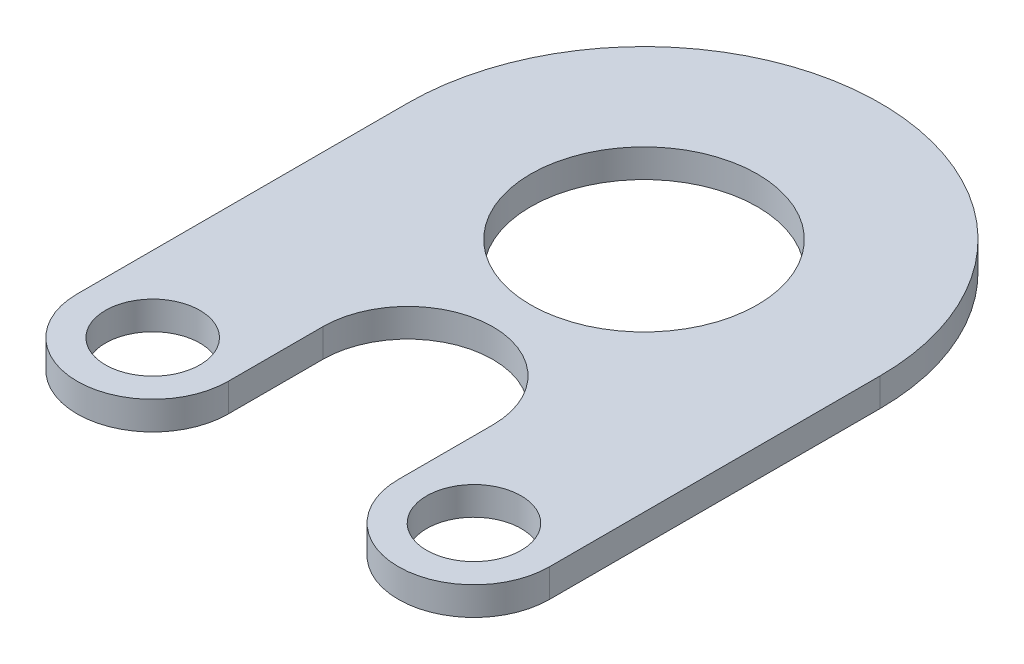
from build123d import *

# Parameters (mm, degrees)
SKETCH1_R           = 12
SKETCH1_R_2         = 5
BOSS_EXTRUDE2_DEPTH = 1.5


with BuildPart() as part:
    # Sketch1 → Boss-Extrude2 (new body, symmetric)
    with BuildSketch(Plane(origin=(0, 0, 0), x_dir=(1, 0, 0), z_dir=(0, 1, 0))):
        with BuildLine():
            Line((-25, 0), (-25, -35))
            ThreePointArc((-25, -35), (-17, -43), (-9, -35))
            Line((-9, -35), (-9, -25))
            ThreePointArc((-9, -25), (0, -16), (9, -25))
            Line((9, -25), (9, -35))
            ThreePointArc((9, -35), (17, -43), (25, -35))
            Line((25, -35), (25, 0))
            ThreePointArc((25, 0), (0, 25), (-25, 0))
        make_face()
        Circle(SKETCH1_R, mode=Mode.SUBTRACT)
        with Locations((17, -35)):
            Circle(SKETCH1_R_2, mode=Mode.SUBTRACT)
        with Locations((-17, -35)):
            Circle(SKETCH1_R_2, mode=Mode.SUBTRACT)
    extrude(amount=BOSS_EXTRUDE2_DEPTH, both=True)


solid = part.part
